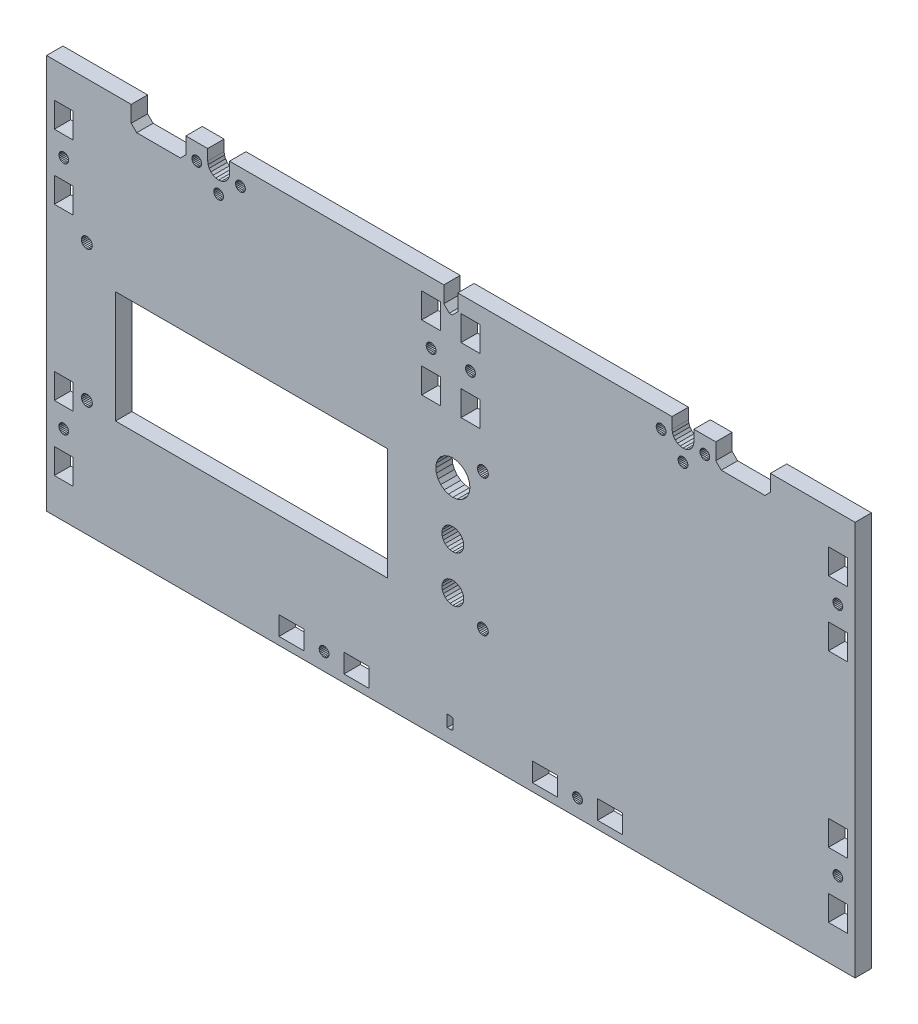
from build123d import *

# Parameters (mm, degrees)
SKETCH1_W           = 6.900001918
SKETCH1_H           = 9.199995837
SKETCH1_W_2         = 6.900001917
SKETCH1_H_2         = 9.1999977
SKETCH1_W_3         = 9.1999977
SKETCH1_H_3         = 6.900001917
SKETCH1_W_4         = 9.199995837
SKETCH1_H_4         = 9.199995838
SKETCH1_W_5         = 99.49999204
SKETCH1_H_5         = 40.99999672
BOSS_EXTRUDE1_DEPTH = 6


with BuildPart() as part:
    # Sketch1 → Boss-Extrude1 (new body)
    with BuildSketch(Plane.XY):
        Polygon((-18.081119656, -260.396542186), (-17.944823005, -259.361266337), (-17.944823005, -255.361267617), (-9.944825565, -255.361267617), (-9.944825565, -261.361265697), (-7.944826205, -263.361265057), (8.055168675, -263.361265057), (10.055168035, -261.361265697), (10.055168035, -255.361267617), (41.055158115, -255.361267617), (41.055158115, -399.861248897), (-254.944747165, -399.861248897), (-254.944747165, -255.361267617), (-223.944757085, -255.361267617), (-223.944757085, -261.361265697), (-221.944757725, -263.361265057), (-205.944762845, -263.361265057), (-203.944763485, -261.361265697), (-203.944763485, -255.361267617), (-195.944766045, -255.361267617), (-195.944766045, -259.361266337), (-195.808469394, -260.396542186), (-195.408867832, -261.361265697), (-194.773193545, -262.189692556), (-193.944766685, -262.825366843), (-192.980043174, -263.224968405), (-191.944767325, -263.361265057), (-190.909491476, -263.224968405), (-189.944767965, -262.825366843), (-189.116341106, -262.189692556), (-188.480666819, -261.361265697), (-188.081065256, -260.396542186), (-187.944768605, -259.361266337), (-187.944768605, -255.361267617), (-109.494791325, -255.361267617), (-109.494791325, -261.361265697), (-107.494791965, -263.361265057), (-106.394797085, -263.361265057), (-104.394797725, -261.361265697), (-104.394797725, -255.361267617), (-25.944820445, -255.361267617), (-25.944820445, -259.361266337), (-25.808523794, -260.396542186), (-25.408922232, -261.361265697), (-24.773247945, -262.189692556), (-23.944821085, -262.825366843), (-22.980097574, -263.224968405), (-21.944821725, -263.361265057), (-20.909545876, -263.224968405), (-19.944822365, -262.825366843), (-19.116395506, -262.189692556), (-18.480721219, -261.361265697), align=None)
        Polygon((36.029171195, -285.785270406), (36.315498884, -285.412120896), (36.495491995, -284.977579088), (36.556884293, -284.511258289), (36.495491995, -284.044937489), (36.315498884, -283.610395681), (36.029171195, -283.237246171), (35.656021685, -282.950918481), (35.221479877, -282.770925371), (34.755159077, -282.709533073), (34.288838277, -282.770925371), (33.854296469, -282.950918481), (33.481146959, -283.237246171), (33.19481927, -283.610395681), (33.014826159, -284.044937489), (32.953433861, -284.511258289), (33.014826159, -284.977579088), (33.19481927, -285.412120896), (33.481146959, -285.785270406), (33.854296469, -286.071598096), (34.288838277, -286.251591206), (34.755159077, -286.312983504), (35.221479877, -286.251591206), (35.656021685, -286.071598096), align=None, mode=Mode.SUBTRACT)
        Polygon((-190.385922097, -266.961263905), (-190.671975526, -266.588471818), (-191.044767613, -266.302418389), (-191.478893193, -266.122597686), (-191.944767325, -266.061264193), (-192.410641457, -266.122597686), (-192.844767037, -266.302418389), (-193.217559124, -266.588471818), (-193.503612553, -266.961263905), (-193.683433256, -267.395389485), (-193.744766749, -267.861263617), (-193.683433256, -268.327137749), (-193.503612553, -268.761263329), (-193.217559124, -269.134055415), (-192.844767037, -269.420108845), (-192.410641457, -269.599929548), (-191.944767325, -269.661263041), (-191.478893193, -269.599929548), (-191.044767613, -269.420108845), (-190.671975526, -269.134055415), (-190.385922097, -268.761263329), (-190.206101394, -268.327137749), (-190.144767901, -267.861263617), (-190.206101394, -267.395389485), align=None, mode=Mode.SUBTRACT)
        Polygon((-13.480066564, -259.622599766), (-13.945940696, -259.561266273), (-14.411814828, -259.622599766), (-14.845940408, -259.802420469), (-15.218732495, -260.088473898), (-15.504785924, -260.461265985), (-15.684606627, -260.895391565), (-15.74594012, -261.361265697), (-15.684606627, -261.827139829), (-15.504785924, -262.261265409), (-15.218732495, -262.634057495), (-14.845940408, -262.920110925), (-14.411814828, -263.099931628), (-13.945940696, -263.161265121), (-13.480066564, -263.099931628), (-13.045940984, -262.920110925), (-12.673148897, -262.634057495), (-12.387095468, -262.261265409), (-12.207274765, -261.827139829), (-12.145941272, -261.361265697), (-12.207274765, -260.895391565), (-12.387095468, -260.461265985), (-12.673148897, -260.088473898), (-13.045940984, -259.802420469), align=None, mode=Mode.SUBTRACT)
        Polygon((-185.684552227, -260.895391565), (-185.74588572, -261.361265697), (-185.684552227, -261.827139829), (-185.504731524, -262.261265409), (-185.218678095, -262.634057495), (-184.845886008, -262.920110925), (-184.411760428, -263.099931628), (-183.945886296, -263.161265121), (-183.480012164, -263.099931628), (-183.045886584, -262.920110925), (-182.673094497, -262.634057495), (-182.387041068, -262.261265409), (-182.207220365, -261.827139829), (-182.145886872, -261.361265697), (-182.207220365, -260.895391565), (-182.387041068, -260.461265985), (-182.673094497, -260.088473898), (-183.045886584, -259.802420469), (-183.480012164, -259.622599766), (-183.945886296, -259.561266273), (-184.411760428, -259.622599766), (-184.845886008, -259.802420469), (-185.218678095, -260.088473898), (-185.504731524, -260.461265985), align=None, mode=Mode.SUBTRACT)
        with Locations((34.755158116, -272.611262238)):
            Rectangle(SKETCH1_W, SKETCH1_H, mode=Mode.SUBTRACT)
        with Locations((-248.644747167, -296.511253036)):
            Rectangle(SKETCH1_W_2, SKETCH1_H_2, mode=Mode.SUBTRACT)
        Polygon((-198.144765341, -261.361265697), (-198.206098834, -260.895391565), (-198.385919537, -260.461265985), (-198.671972966, -260.088473898), (-199.044765053, -259.802420469), (-199.478890633, -259.622599766), (-199.944764765, -259.561266273), (-200.410638897, -259.622599766), (-200.844764477, -259.802420469), (-201.217556564, -260.088473898), (-201.503609993, -260.461265985), (-201.683430696, -260.895391565), (-201.744764189, -261.361265697), (-201.683430696, -261.827139829), (-201.503609993, -262.261265409), (-201.217556564, -262.634057495), (-200.844764477, -262.920110925), (-200.410638897, -263.099931628), (-199.944764765, -263.161265121), (-199.478890633, -263.099931628), (-199.044765053, -262.920110925), (-198.671972966, -262.634057495), (-198.385919537, -262.261265409), (-198.206098834, -261.827139829), align=None, mode=Mode.SUBTRACT)
        Polygon((-59.270801285, -394.83526303), (-58.984473595, -394.46211352), (-58.804480485, -394.027571712), (-58.743088187, -393.561250913), (-58.804480485, -393.094930113), (-58.984473595, -392.660388305), (-59.270801285, -392.287238795), (-59.643950795, -392.000911105), (-60.078492603, -391.820917995), (-60.544813403, -391.759525697), (-61.011134202, -391.820917995), (-61.44567601, -392.000911105), (-61.81882552, -392.287238795), (-62.10515321, -392.660388305), (-62.28514632, -393.094930113), (-62.346538618, -393.561250913), (-62.28514632, -394.027571712), (-62.10515321, -394.46211352), (-61.81882552, -394.83526303), (-61.44567601, -395.12159072), (-61.011134202, -395.30158383), (-60.544813403, -395.362976128), (-60.078492603, -395.30158383), (-59.643950795, -395.12159072), align=None, mode=Mode.SUBTRACT)
        Polygon((-30.844818877, -262.920110925), (-30.410693297, -263.099931628), (-29.944819165, -263.161265121), (-29.478945033, -263.099931628), (-29.044819453, -262.920110925), (-28.672027366, -262.634057495), (-28.385973937, -262.261265409), (-28.206153234, -261.827139829), (-28.144819741, -261.361265697), (-28.206153234, -260.895391565), (-28.385973937, -260.461265985), (-28.672027366, -260.088473898), (-29.044819453, -259.802420469), (-29.478945033, -259.622599766), (-29.944819165, -259.561266273), (-30.410693297, -259.622599766), (-30.844818877, -259.802420469), (-31.217610964, -260.088473898), (-31.503664393, -260.461265985), (-31.683485096, -260.895391565), (-31.744818589, -261.361265697), (-31.683485096, -261.827139829), (-31.503664393, -262.261265409), (-31.217610964, -262.634057495), align=None, mode=Mode.SUBTRACT)
        with Locations((-248.644747167, -272.711262207)):
            Rectangle(SKETCH1_W_2, SKETCH1_H, mode=Mode.SUBTRACT)
        with Locations((-72.444808182, -393.561249952)):
            Rectangle(SKETCH1_W_3, SKETCH1_H_3, mode=Mode.SUBTRACT)
        Polygon((-154.905115455, -394.46211352), (-154.618787766, -394.83526303), (-154.245638256, -395.12159072), (-153.811096448, -395.30158383), (-153.344775648, -395.362976128), (-152.878454848, -395.30158383), (-152.44391304, -395.12159072), (-152.07076353, -394.83526303), (-151.784435841, -394.46211352), (-151.60444273, -394.027571712), (-151.543050432, -393.561250913), (-151.60444273, -393.094930113), (-151.784435841, -392.660388305), (-152.07076353, -392.287238795), (-152.44391304, -392.000911105), (-152.878454848, -391.820917995), (-153.344775648, -391.759525697), (-153.811096448, -391.820917995), (-154.245638256, -392.000911105), (-154.618787766, -392.287238795), (-154.905115455, -392.660388305), (-155.085108566, -393.094930113), (-155.146500864, -393.561250913), (-155.085108566, -394.027571712), align=None, mode=Mode.SUBTRACT)
        Polygon((-246.904413288, -285.077579056), (-246.84302099, -284.611258257), (-246.904413288, -284.144937457), (-247.084406398, -283.710395649), (-247.370734088, -283.337246139), (-247.743883598, -283.050918449), (-248.178425406, -282.870925339), (-248.644746206, -282.809533041), (-249.111067006, -282.870925339), (-249.545608814, -283.050918449), (-249.918758324, -283.337246139), (-250.205086013, -283.710395649), (-250.385079123, -284.144937457), (-250.446471421, -284.611258257), (-250.385079123, -285.077579056), (-250.205086013, -285.512120864), (-249.918758324, -285.885270374), (-249.545608814, -286.171598064), (-249.111067006, -286.351591174), (-248.644746206, -286.412983472), (-248.178425406, -286.351591174), (-247.743883598, -286.171598064), (-247.370734088, -285.885270374), (-247.084406398, -285.512120864), align=None, mode=Mode.SUBTRACT)
        with Locations((-165.244770427, -393.561249952)):
            Rectangle(SKETCH1_W_3, SKETCH1_H_3, mode=Mode.SUBTRACT)
        with Locations((34.755158116, -296.411253068)):
            Rectangle(SKETCH1_W, SKETCH1_H_2, mode=Mode.SUBTRACT)
        with Locations((-141.444779598, -393.561249952)):
            Rectangle(SKETCH1_W_4, SKETCH1_H_3, mode=Mode.SUBTRACT)
        Polygon((-23.217613524, -269.134055415), (-22.844821437, -269.420108845), (-22.410695857, -269.599929548), (-21.944821725, -269.661263041), (-21.478947593, -269.599929548), (-21.044822013, -269.420108845), (-20.672029926, -269.134055415), (-20.385976497, -268.761263329), (-20.206155794, -268.327137749), (-20.144822301, -267.861263617), (-20.206155794, -267.395389485), (-20.385976497, -266.961263905), (-20.672029926, -266.588471818), (-21.044822013, -266.302418389), (-21.478947593, -266.122597686), (-21.944821725, -266.061264193), (-22.410695857, -266.122597686), (-22.844821437, -266.302418389), (-23.217613524, -266.588471818), (-23.503666953, -266.961263905), (-23.683487656, -267.395389485), (-23.744821149, -267.861263617), (-23.683487656, -268.327137749), (-23.503666953, -268.761263329), align=None, mode=Mode.SUBTRACT)
        Polygon((36.315498884, -369.71039266), (36.029171195, -369.33724315), (35.656021685, -369.05091546), (35.221479877, -368.87092235), (34.755159077, -368.809530052), (34.288838277, -368.87092235), (33.854296469, -369.05091546), (33.481146959, -369.33724315), (33.19481927, -369.71039266), (33.014826159, -370.144934468), (32.953433861, -370.611255267), (33.014826159, -371.077576067), (33.19481927, -371.512117875), (33.481146959, -371.885267385), (33.854296469, -372.171595075), (34.288838277, -372.351588185), (34.755159077, -372.412980483), (35.221479877, -372.351588185), (35.656021685, -372.171595075), (36.029171195, -371.885267385), (36.315498884, -371.512117875), (36.495491995, -371.077576067), (36.556884293, -370.611255267), (36.495491995, -370.144934468), align=None, mode=Mode.SUBTRACT)
        with Locations((34.755158116, -358.711259217)):
            Rectangle(SKETCH1_W, SKETCH1_H_4, mode=Mode.SUBTRACT)
        with Locations((34.755158116, -382.511250047)):
            Rectangle(SKETCH1_W, SKETCH1_H_2, mode=Mode.SUBTRACT)
        Polygon((-249.545608814, -372.171595075), (-249.111067006, -372.351588185), (-248.644746206, -372.412980483), (-248.178425406, -372.351588185), (-247.743883598, -372.171595075), (-247.370734088, -371.885267385), (-247.084406398, -371.512117875), (-246.904413288, -371.077576067), (-246.84302099, -370.611255267), (-246.904413288, -370.144934468), (-247.084406398, -369.71039266), (-247.370734088, -369.33724315), (-247.743883598, -369.05091546), (-248.178425406, -368.87092235), (-248.644746206, -368.809530052), (-249.111067006, -368.87092235), (-249.545608814, -369.05091546), (-249.918758324, -369.33724315), (-250.205086013, -369.71039266), (-250.385079123, -370.144934468), (-250.446471421, -370.611255267), (-250.385079123, -371.077576067), (-250.205086013, -371.512117875), (-249.918758324, -371.885267385), align=None, mode=Mode.SUBTRACT)
        with Locations((-248.644747167, -358.711259217)):
            Rectangle(SKETCH1_W_2, SKETCH1_H_4, mode=Mode.SUBTRACT)
        with Locations((-248.644747167, -382.511250047)):
            Rectangle(SKETCH1_W_2, SKETCH1_H_2, mode=Mode.SUBTRACT)
        Polygon((-102.337752012, -333.308050309), (-102.73735367, -332.343326567), (-103.373028109, -331.514899508), (-104.201455168, -330.879225069), (-105.16617891, -330.479623411), (-106.201455008, -330.343326727), (-107.236731105, -330.479623411), (-108.201454848, -330.879225069), (-109.029881906, -331.514899508), (-109.665556346, -332.343326567), (-110.065158004, -333.308050309), (-110.201454688, -334.343326407), (-110.065158004, -335.378602504), (-109.665556346, -336.343326247), (-109.029881906, -337.171753305), (-108.201454848, -337.807427745), (-107.236731105, -338.207029403), (-106.201455008, -338.343326087), (-105.16617891, -338.207029403), (-104.201455168, -337.807427745), (-103.373028109, -337.171753305), (-102.73735367, -336.343326247), (-102.337752012, -335.378602504), (-102.201455328, -334.343326407), align=None, mode=Mode.SUBTRACT)
        Polygon((-109.665556346, -353.343324887), (-109.029881906, -354.171751945), (-108.201454848, -354.807426385), (-107.236731105, -355.207028043), (-106.201455008, -355.343324727), (-105.16617891, -355.207028043), (-104.201455168, -354.807426385), (-103.373028109, -354.171751945), (-102.73735367, -353.343324887), (-102.337752012, -352.378601144), (-102.201455328, -351.343325047), (-102.337752012, -350.308048949), (-102.73735367, -349.343325207), (-103.373028109, -348.514898148), (-104.201455168, -347.879223709), (-105.16617891, -347.479622051), (-106.201455008, -347.343325367), (-107.236731105, -347.479622051), (-108.201454848, -347.879223709), (-109.029881906, -348.514898148), (-109.665556346, -349.343325207), (-110.065158004, -350.308048949), (-110.201454688, -351.343325047), (-110.065158004, -352.378601144), align=None, mode=Mode.SUBTRACT)
        Polygon((-103.076455258, -309.430669626), (-104.583836105, -308.806292035), (-106.201455008, -308.593328467), (-107.81907391, -308.806292035), (-109.326454758, -309.430669626), (-110.620872037, -310.423910938), (-111.614113348, -311.718328217), (-112.238490939, -313.225709064), (-112.451454508, -314.843327967), (-112.238490939, -316.460946869), (-111.614113348, -317.968327717), (-110.620872037, -319.262744996), (-109.326454758, -320.255986307), (-107.81907391, -320.880363898), (-106.201455008, -321.093327467), (-104.583836105, -320.880363898), (-103.076455258, -320.255986307), (-101.782037979, -319.262744996), (-100.788796667, -317.968327717), (-100.164419076, -316.460946869), (-99.951455508, -314.843327967), (-100.164419076, -313.225709064), (-100.788796667, -311.718328217), (-101.782037979, -310.423910938), align=None, mode=Mode.SUBTRACT)
        with Locations((-179.951449028, -338.143326103)):
            Rectangle(SKETCH1_W_5, SKETCH1_H_5, mode=Mode.SUBTRACT)
        Polygon((-106.220266687, -394.843429536), (-106.159386352, -394.754065136), (-106.139092906, -394.657680203), (-106.139092906, -391.31126252), (-106.159386352, -391.217607795), (-106.220266687, -391.130193542), (-106.463788028, -390.974086453), (-106.829058131, -390.866402574), (-107.262997251, -390.830507947), (-108.280765925, -390.830507947), (-108.280765925, -395.138434776), (-107.262997251, -395.138434776), (-106.819697422, -395.104100268), (-106.463788028, -395.001096743), align=None, mode=Mode.SUBTRACT)
        with Locations((-48.644817352, -393.561249952)):
            Rectangle(SKETCH1_W_4, SKETCH1_H_3, mode=Mode.SUBTRACT)
        Polygon((-238.194746208, -307.343328567), (-238.262894555, -306.825690477), (-238.4626954, -306.343328567), (-238.780532646, -305.929115004), (-239.194746208, -305.611277759), (-239.677108118, -305.411476914), (-240.194746208, -305.343328567), (-240.712384298, -305.411476914), (-241.194746208, -305.611277759), (-241.60895977, -305.929115004), (-241.926797016, -306.343328567), (-242.126597861, -306.825690477), (-242.194746208, -307.343328567), (-242.126597861, -307.860966657), (-241.926797016, -308.343328567), (-241.60895977, -308.757542129), (-241.194746208, -309.075379374), (-240.712384298, -309.275180219), (-240.194746208, -309.343328567), (-239.677108118, -309.275180219), (-239.194746208, -309.075379374), (-238.780532646, -308.757542129), (-238.4626954, -308.343328567), (-238.262894555, -307.860966657), align=None, mode=Mode.SUBTRACT)
        Polygon((-238.180298343, -357.343324567), (-238.24844669, -356.825686477), (-238.448247535, -356.343324567), (-238.76608478, -355.929111004), (-239.180298343, -355.611273759), (-239.662660252, -355.411472914), (-240.180298343, -355.343324567), (-240.697936433, -355.411472914), (-241.180298343, -355.611273759), (-241.594511905, -355.929111004), (-241.91234915, -356.343324567), (-242.112149995, -356.825686477), (-242.180298343, -357.343324567), (-242.112149995, -357.860962657), (-241.91234915, -358.343324567), (-241.594511905, -358.757538129), (-241.180298343, -359.075375374), (-240.697936433, -359.275176219), (-240.180298343, -359.343324567), (-239.662660252, -359.275176219), (-239.180298343, -359.075375374), (-238.76608478, -358.757538129), (-238.448247535, -358.343324567), (-238.24844669, -357.860962657), align=None, mode=Mode.SUBTRACT)
        Polygon((-93.201455808, -357.343324567), (-93.269604155, -356.825686477), (-93.469405, -356.343324567), (-93.787242245, -355.929111004), (-94.201455808, -355.611273759), (-94.683817717, -355.411472914), (-95.201455808, -355.343324567), (-95.719093898, -355.411472914), (-96.201455808, -355.611273759), (-96.61566937, -355.929111004), (-96.933506615, -356.343324567), (-97.13330746, -356.825686477), (-97.201455808, -357.343324567), (-97.13330746, -357.860962657), (-96.933506615, -358.343324567), (-96.61566937, -358.757538129), (-96.201455808, -359.075375374), (-95.719093898, -359.275176219), (-95.201455808, -359.343324567), (-94.683817717, -359.275176219), (-94.201455808, -359.075375374), (-93.787242245, -358.757538129), (-93.469405, -358.343324567), (-93.269604155, -357.860962657), align=None, mode=Mode.SUBTRACT)
        Polygon((-93.201455808, -307.343328567), (-93.269604155, -306.825690477), (-93.469405, -306.343328567), (-93.787242245, -305.929115004), (-94.201455808, -305.611277759), (-94.683817717, -305.411476914), (-95.201455808, -305.343328567), (-95.719093898, -305.411476914), (-96.201455808, -305.611277759), (-96.61566937, -305.929115004), (-96.933506615, -306.343328567), (-97.13330746, -306.825690477), (-97.201455808, -307.343328567), (-97.13330746, -307.860966657), (-96.933506615, -308.343328567), (-96.61566937, -308.757542129), (-96.201455808, -309.075379374), (-95.719093898, -309.275180219), (-95.201455808, -309.343328567), (-94.683817717, -309.275180219), (-94.201455808, -309.075379374), (-93.787242245, -308.757542129), (-93.469405, -308.343328567), (-93.269604155, -307.860966657), align=None, mode=Mode.SUBTRACT)
        Polygon((-112.58444947, -278.722102536), (-112.40445636, -278.287560728), (-112.343064062, -277.821239928), (-112.40445636, -277.354919128), (-112.58444947, -276.92037732), (-112.87077716, -276.54722781), (-113.24392667, -276.260900121), (-113.678468478, -276.08090701), (-114.144789278, -276.019514712), (-114.611110078, -276.08090701), (-115.045651886, -276.260900121), (-115.418801396, -276.54722781), (-115.705129085, -276.92037732), (-115.885122195, -277.354919128), (-115.946514493, -277.821239928), (-115.885122195, -278.287560728), (-115.705129085, -278.722102536), (-115.418801396, -279.095252046), (-115.045651886, -279.381579735), (-114.611110078, -279.561572845), (-114.144789278, -279.622965143), (-113.678468478, -279.561572845), (-113.24392667, -279.381579735), (-112.87077716, -279.095252046), align=None, mode=Mode.SUBTRACT)
        with Locations((-114.144790239, -265.921243878)):
            Rectangle(SKETCH1_W_2, SKETCH1_H, mode=Mode.SUBTRACT)
        with Locations((-114.144790239, -289.721234707)):
            Rectangle(SKETCH1_W_2, SKETCH1_H_2, mode=Mode.SUBTRACT)
        with Locations((-99.744794847, -289.721234707)):
            Rectangle(SKETCH1_W_2, SKETCH1_H_2, mode=Mode.SUBTRACT)
        Polygon((-98.470781768, -276.54722781), (-98.843931278, -276.260900121), (-99.278473086, -276.08090701), (-99.744793886, -276.019514712), (-100.211114686, -276.08090701), (-100.645656494, -276.260900121), (-101.018806004, -276.54722781), (-101.305133693, -276.92037732), (-101.485126803, -277.354919128), (-101.546519101, -277.821239928), (-101.485126803, -278.287560728), (-101.305133693, -278.722102536), (-101.018806004, -279.095252046), (-100.645656494, -279.381579735), (-100.211114686, -279.561572845), (-99.744793886, -279.622965143), (-99.278473086, -279.561572845), (-98.843931278, -279.381579735), (-98.470781768, -279.095252046), (-98.184454078, -278.722102536), (-98.004460968, -278.287560728), (-97.94306867, -277.821239928), (-98.004460968, -277.354919128), (-98.184454078, -276.92037732), align=None, mode=Mode.SUBTRACT)
        with Locations((-99.744794847, -265.921243878)):
            Rectangle(SKETCH1_W_2, SKETCH1_H, mode=Mode.SUBTRACT)
    extrude(amount=BOSS_EXTRUDE1_DEPTH)


solid = part.part
